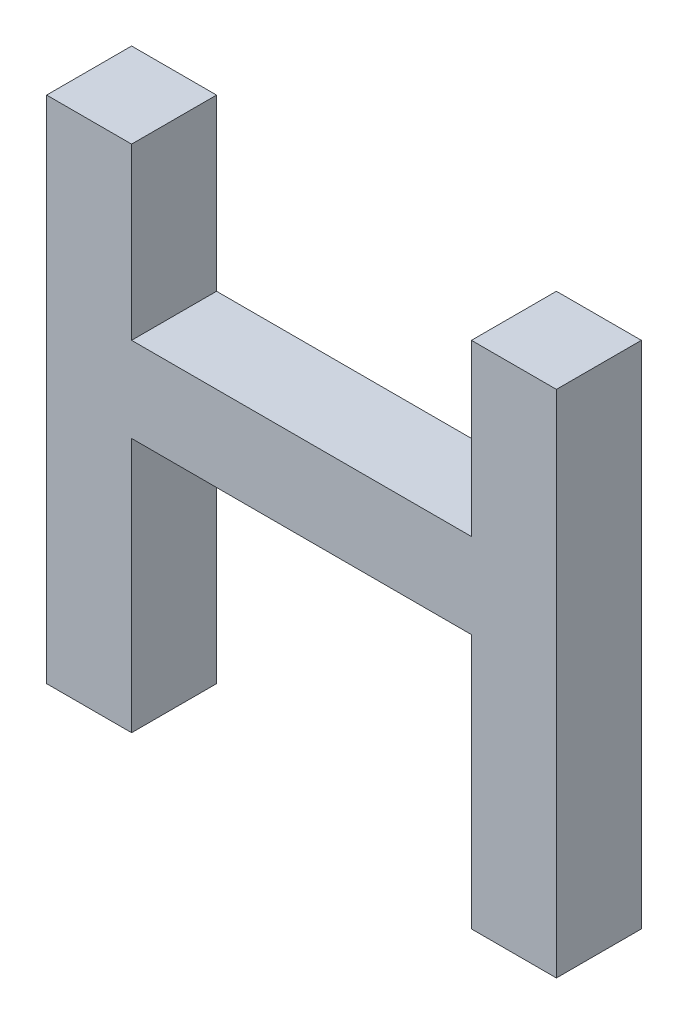
from build123d import *

# Parameters (mm, degrees)
BOSS_EXTRUDE1_DEPTH = 25.4


with BuildPart() as part:
    # Sketch1 → Boss-Extrude1 (new body)
    with BuildSketch(Plane.XY):
        Polygon((50.8, 0), (-50.8, 0), (-50.8, -76.2), (-76.2, -76.2), (-76.2, 76.2), (-50.8, 76.2), (-50.8, 25.4), (50.8, 25.4), (50.8, 76.2), (76.2, 76.2), (76.2, -76.2), (50.8, -76.2), align=None)
    extrude(amount=BOSS_EXTRUDE1_DEPTH)


solid = part.part
